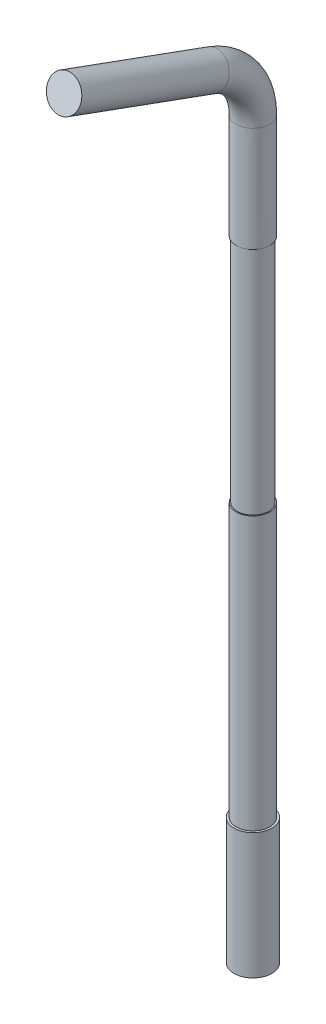
from build123d import *

# Parameters (mm, degrees)
SKETCH2_R         = 0.8
SKETCH4_R         = 0.9
EXTRUDE1_DEPTH    = 6
SKETCH5_OUTSIDE_W = 12.282
SKETCH5_OUTSIDE_H = 20.656
SKETCH5_OUTSIDE_R = 0.75
EXTRUDE3_DEPTH    = 11


with BuildPart() as part:
    # Sweep1: sweep along a path in Sketch1
    with BuildLine(Plane(origin=(0, 0, 0), x_dir=(0, 0, -1), z_dir=(1, 0, 0))) as sweep1_path:
        Line((-7.5, 0), (-7.5, 35))
        ThreePointArc((-7.5, 35), (-8.042543867, 36.720729309), (-9.47393957, 37.819077862))
        Line((-9.47393957, 37.819077862), (-16.5, 40.376354723))
    # Sketch2 → Sweep1 (sweep)
    with BuildSketch(Plane(origin=(0, 0, 0), x_dir=(1, 0, 0), z_dir=(0, 1, 0))):
        with Locations((0, -7.5)):
            Circle(SKETCH2_R)
    sweep(path=sweep1_path.line)

    # Sketch4 → Extrude1 (add)
    with BuildSketch(Plane(origin=(0, 0, 0), x_dir=(1, 0, 0), z_dir=(0, 1, 0))):
        with Locations((0, -7.5)):
            Circle(SKETCH4_R)
    extrude(amount=EXTRUDE1_DEPTH)

    # Sketch5 outside → Extrude3 (cut)
    with BuildSketch(Plane(origin=(0, 19, 0), x_dir=(-1, 0, 0), z_dir=(0, 1, 0))):
        with Locations((0, 11.687)):
            Rectangle(SKETCH5_OUTSIDE_W, SKETCH5_OUTSIDE_H)
        with Locations((0, 7.5)):
            Circle(SKETCH5_OUTSIDE_R, mode=Mode.SUBTRACT)
    extrude(amount=EXTRUDE3_DEPTH, mode=Mode.SUBTRACT)


solid = part.part
